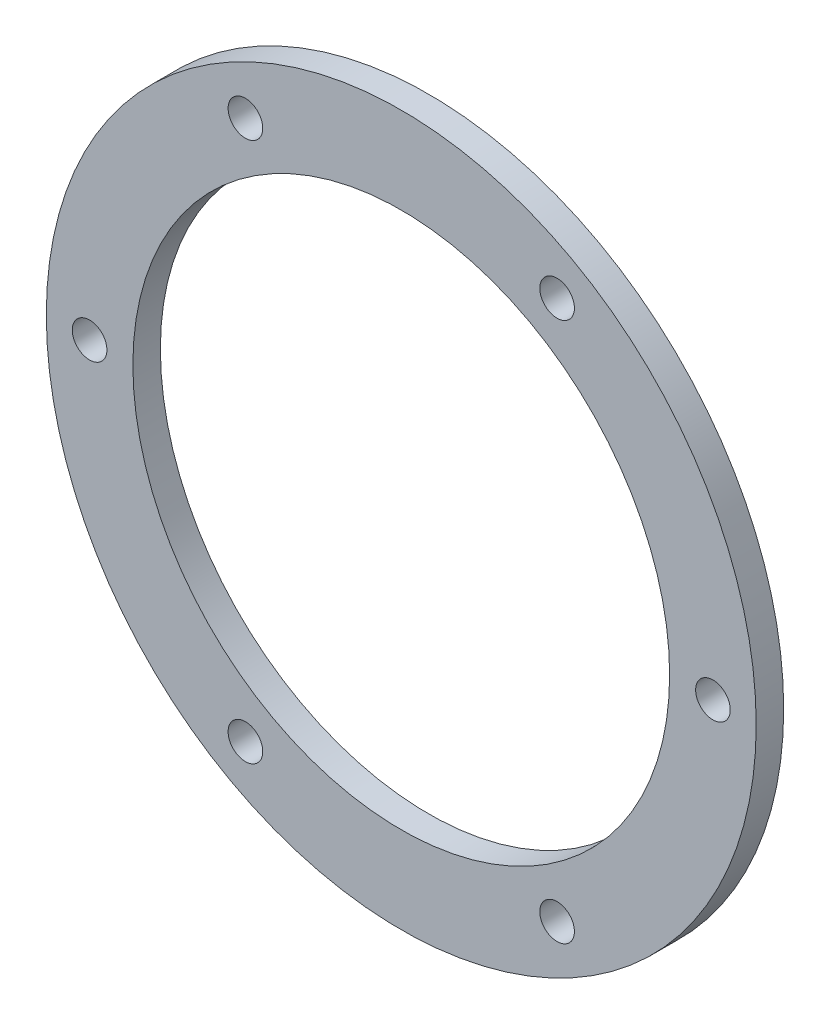
from build123d import *

# Parameters (mm, degrees)
SKETCH1_R           = 41
SKETCH1_R_2         = 31
BOSS_EXTRUDE1_DEPTH = 3.175
SKETCH2_R           = 2
CUT_EXTRUDE2_DEPTH  = 4.175


with BuildPart() as part:
    # Sketch1 → Boss-Extrude1 (new body)
    with BuildSketch(Plane.XY):
        Circle(SKETCH1_R)
        Circle(SKETCH1_R_2, mode=Mode.SUBTRACT)
    extrude(amount=BOSS_EXTRUDE1_DEPTH)

    # Sketch2 → Cut-Extrude2 (cut, through all)
    with BuildSketch(Plane.XY.offset(3.175)):
        with Locations((-18, 31.176914536)):
            Circle(SKETCH2_R)
        with Locations((18, 31.176914536)):
            Circle(SKETCH2_R)
        with Locations((36, 0)):
            Circle(SKETCH2_R)
        with Locations((18, -31.176914536)):
            Circle(SKETCH2_R)
        with Locations((-18, -31.176914536)):
            Circle(SKETCH2_R)
        with Locations((-36, 0)):
            Circle(SKETCH2_R)
    extrude(amount=-CUT_EXTRUDE2_DEPTH, mode=Mode.SUBTRACT)


solid = part.part
